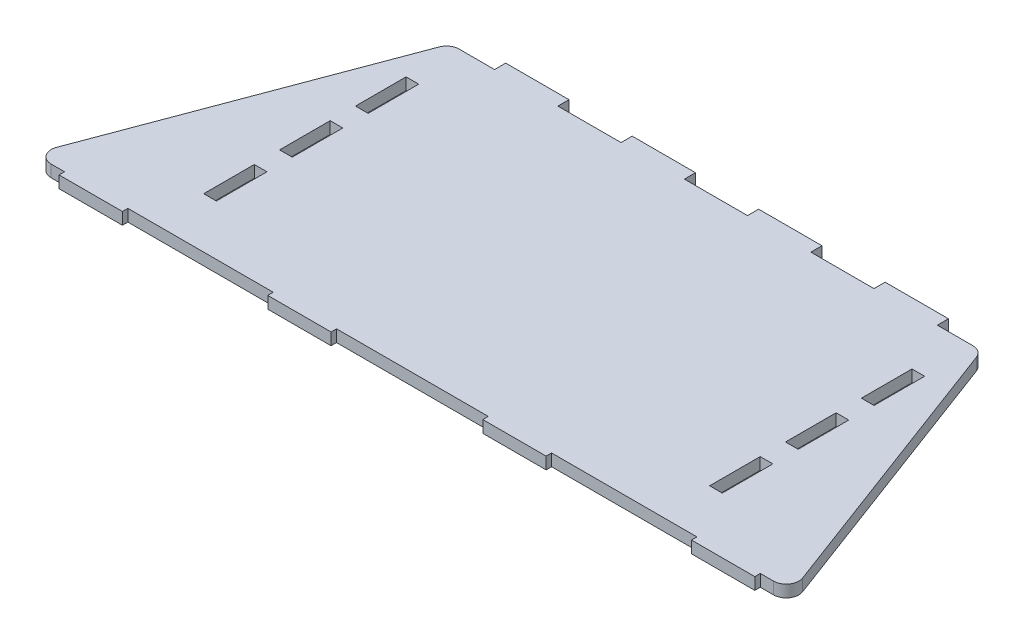
from build123d import *

# Parameters (mm, degrees)
BOSS_EXTRUDE1_DEPTH = 6
SKETCH2_W           = 31.8008
SKETCH2_H           = 5.588
SKETCH2_H_2         = 2.7432
TABS_DEPTH          = 6
FILLET2_R           = 6.35
FILLET3_R           = 6.35
SKETCH5_W           = 6.35
SKETCH5_H           = 25.4
TAB_CUT_OUTS_DEPTH  = 6


with BuildPart() as part:
    # Sketch1 → Boss-Extrude1 (new body)
    with BuildSketch(Plane(origin=(0, 0, 0), x_dir=(1, 0, 0), z_dir=(0, 1, 0))):
        Polygon((-190.5, -76.2), (190.5, -76.2), (133.35, 76.2), (-133.35, 76.2), align=None)
    extrude(amount=BOSS_EXTRUDE1_DEPTH)

    # Sketch2 → Tabs (add)
    with BuildSketch(Plane(origin=(0, 6, 0), x_dir=(1, 0, 0), z_dir=(0, 1, 0))):
        with Locations((95.25, 78.994)):
            Rectangle(SKETCH2_W, SKETCH2_H)
        with Locations((-31.75, 78.994)):
            Rectangle(SKETCH2_W, SKETCH2_H)
        with Locations((-95.25, 78.994)):
            Rectangle(SKETCH2_W, SKETCH2_H)
        with Locations((31.75, 78.994)):
            Rectangle(SKETCH2_W, SKETCH2_H)
        with Locations((53.975, -77.5716)):
            Rectangle(SKETCH2_W, SKETCH2_H_2)
        with Locations((-53.975, -77.5716)):
            Rectangle(SKETCH2_W, SKETCH2_H_2)
        with Locations((-158.75, -77.5716)):
            Rectangle(SKETCH2_W, SKETCH2_H_2)
        with Locations((158.75, -77.5716)):
            Rectangle(SKETCH2_W, SKETCH2_H_2)
    extrude(amount=-TABS_DEPTH)

    # Fillet2
    fillet2_edges = [part.edges().sort_by_distance(p)[0] for p in [
        (190.5, 3, 76.2),
        (-190.5, 3, 76.2),
    ]]
    fillet(fillet2_edges, radius=FILLET2_R)

    # Fillet3
    fillet3_edges = [part.edges().sort_by_distance(p)[0] for p in [
        (-133.35, 3, -76.2),
        (133.35, 3, -76.2),
    ]]
    fillet(fillet3_edges, radius=FILLET3_R)

    # Sketch5 → Tab Cut Outs (cut)
    with BuildSketch(Plane(origin=(0, 6, 0), x_dir=(1, 0, 0), z_dir=(0, 1, 0))):
        with Locations((127, -38.1)):
            Rectangle(SKETCH5_W, SKETCH5_H)
        with Locations((127, 38.1)):
            Rectangle(SKETCH5_W, SKETCH5_H)
        with Locations((127, 0)):
            Rectangle(SKETCH5_W, SKETCH5_H)
    tab_cut_outs = extrude(amount=-TAB_CUT_OUTS_DEPTH, mode=Mode.SUBTRACT)

    # Mirror1: Tab Cut Outs across plane
    add(tab_cut_outs.mirror(Plane.ZY), mode=Mode.SUBTRACT)


solid = part.part
